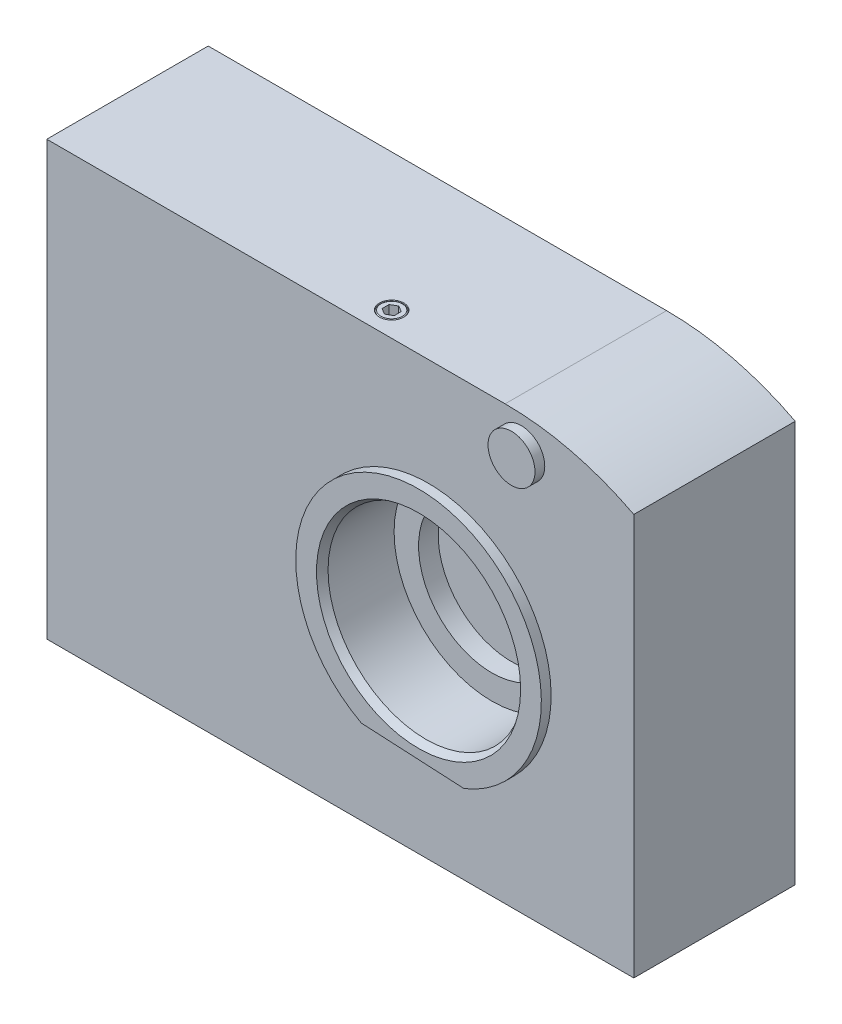
from build123d import *

# Parameters (mm, degrees)
BOSS_EXTRUDE1_DEPTH = 33
BOSS_EXTRUDE2_DEPTH = 2
CUT_EXTRUDE1_DEPTH  = 9.3
CUT_EXTRUDE2_DEPTH  = 9.3
CUT_EXTRUDE3_DEPTH  = 9.3
CUT_EXTRUDE4_DEPTH  = 9.3
SKETCH16_R          = 4.8
BOSS_EXTRUDE3_DEPTH = 2
CUT_EXTRUDE5_DEPTH  = 3


with BuildPart() as part:
    # Sketch1 → Boss-Extrude1 (new body)
    with BuildSketch(Plane.XY):
        with BuildLine():
            Line((0, 0), (120, 0))
            Line((120, 0), (120, 82.069852679))
            ThreePointArc((120, 82.069852679), (107.237326126, 86.869132207), (93.7, 88.5))
            Line((93.7, 88.5), (0, 88.5))
            Line((0, 88.5), (0, 0))
        make_face()
    extrude(amount=-BOSS_EXTRUDE1_DEPTH)

    # Sketch2 → Boss-Extrude2 (add)
    with BuildSketch(Plane.XY):
        with BuildLine():
            Line((66.324935076, 19.280574737), (87.288545319, 18.181918478))
            ThreePointArc((87.288545319, 18.181918478), (79.313632502, 66.565601322), (66.324935076, 19.280574737))
        make_face()
    extrude(amount=BOSS_EXTRUDE2_DEPTH)

    # Sketch3 → Cut-Revolve1 (revolve, cut)
    with BuildSketch(Plane(origin=(78, 0, 0), x_dir=(0, 0, -1), z_dir=(1, 0, 0))):
        Polygon((-2, 41.5), (-2, 62.366025404), (-0.5, 61.5), (13, 61.5), (13, 56.5), (17, 56.5), (17, 61.5), (28.5, 61.5), (30, 62.366025404), (30, 72.5), (33, 72.5), (33, 41.5), align=None)
    revolve(axis=Axis((78, 41.5, -33), (0, 0, 1)), mode=Mode.SUBTRACT)

    # Sketch4 → Cut-Revolve2 (revolve, cut)
    with BuildSketch(Plane(origin=(19.5, 0, 0), x_dir=(0, 0, -1), z_dir=(1, 0, 0))):
        Polygon((23.7, 8), (26.7, 11), (26.7, 12.4), (26.1, 13), (20.7, 13), (20.7, 13.5), (33, 13.5), (33, 8), align=None)
    revolve(axis=Axis((19.5, 8, -33), (0, 0, 1)), mode=Mode.SUBTRACT)

    # Sketch5 → Cut-Revolve3 (revolve, cut)
    with BuildSketch(Plane(origin=(103.5, 0, 0), x_dir=(0, 0, -1), z_dir=(1, 0, 0))):
        Polygon((23.7, 6.5), (26.7, 9.5), (26.7, 10.9), (26.1, 11.5), (20.7, 11.5), (20.7, 12), (33, 12), (33, 6.5), align=None)
    revolve(axis=Axis((103.5, 6.5, -33), (0, 0, 1)), mode=Mode.SUBTRACT)

    # Sketch6 → Cut-Revolve4 (revolve, cut)
    with BuildSketch(Plane(origin=(11.5, 0, 0), x_dir=(0, 0, -1), z_dir=(1, 0, 0))):
        Polygon((23.7, 58), (26.7, 61), (26.7, 62.4), (26.1, 63), (20.7, 63), (20.7, 63.5), (33, 63.5), (33, 58), align=None)
    revolve(axis=Axis((11.5, 58, -33), (0, 0, 1)), mode=Mode.SUBTRACT)

    # Sketch7 → Cut-Revolve5 (revolve, cut)
    with BuildSketch(Plane(origin=(107, 0, 0), x_dir=(0, 0, -1), z_dir=(1, 0, 0))):
        Polygon((23.7, 49), (26.7, 52), (26.7, 53.4), (26.1, 54), (20.7, 54), (20.7, 54.5), (33, 54.5), (33, 49), align=None)
    revolve(axis=Axis((107, 49, -33), (0, 0, 1)), mode=Mode.SUBTRACT)

    # Sketch8 → Cut-Extrude1 (cut)
    with BuildSketch(Plane.XY.offset(-33)):
        Polygon((17, 9.443375673), (17, 6.556624327), (19.5, 5.113248654), (22, 6.556624327), (22, 9.443375673), (19.5, 10.886751346), align=None)
    extrude(amount=CUT_EXTRUDE1_DEPTH, mode=Mode.SUBTRACT)

    # Sketch9 → Cut-Extrude2 (cut)
    with BuildSketch(Plane.XY.offset(-33)):
        Polygon((101, 7.943375673), (101, 5.056624327), (103.5, 3.613248654), (106, 5.056624327), (106, 7.943375673), (103.5, 9.386751346), align=None)
    extrude(amount=CUT_EXTRUDE2_DEPTH, mode=Mode.SUBTRACT)

    # Sketch10 → Cut-Extrude3 (cut)
    with BuildSketch(Plane.XY.offset(-33)):
        Polygon((9, 59.443375673), (9, 56.556624327), (11.5, 55.113248654), (14, 56.556624327), (14, 59.443375673), (11.5, 60.886751346), align=None)
    extrude(amount=CUT_EXTRUDE3_DEPTH, mode=Mode.SUBTRACT)

    # Sketch11 → Cut-Extrude4 (cut)
    with BuildSketch(Plane.XY.offset(-33)):
        Polygon((104.5, 50.443375673), (104.5, 47.556624327), (107, 46.113248654), (109.5, 47.556624327), (109.5, 50.443375673), (107, 51.886751346), align=None)
    extrude(amount=CUT_EXTRUDE4_DEPTH, mode=Mode.SUBTRACT)

    # Sketch12 → Cut-Revolve6 (revolve, cut)
    with BuildSketch(Plane(origin=(0, 14.5, 0), x_dir=(1, 0, 0), z_dir=(0, 1, 0))):
        Polygon((46, 11.480584363), (43.5415, 12.9), (43.5415, 32.4585), (43, 33), (46, 33), align=None)
    revolve(axis=Axis((46, 14.5, -33), (0, 0, 1)), mode=Mode.SUBTRACT)

    # Sketch13 → Cut-Revolve7 (revolve, cut)
    with BuildSketch(Plane(origin=(0, 14.5, 0), x_dir=(1, 0, 0), z_dir=(0, 1, 0))):
        Polygon((110, 11.480584363), (107.5415, 12.9), (107.5415, 32.4585), (107, 33), (110, 33), align=None)
    revolve(axis=Axis((110, 14.5, -33), (0, 0, 1)), mode=Mode.SUBTRACT)

    # Sketch14 → Cut-Revolve8 (revolve, cut)
    with BuildSketch(Plane(origin=(0, 68.5, 0), x_dir=(1, 0, 0), z_dir=(0, 1, 0))):
        Polygon((46, 11.480584363), (43.5415, 12.9), (43.5415, 32.4585), (43, 33), (46, 33), align=None)
    revolve(axis=Axis((46, 68.5, -33), (0, 0, 1)), mode=Mode.SUBTRACT)

    # Sketch15 → Cut-Revolve9 (revolve, cut)
    with BuildSketch(Plane(origin=(0, 68.5, 0), x_dir=(1, 0, 0), z_dir=(0, 1, 0))):
        Polygon((110, 11.480584363), (107.5415, 12.9), (107.5415, 32.4585), (107, 33), (110, 33), align=None)
    revolve(axis=Axis((110, 68.5, -33), (0, 0, 1)), mode=Mode.SUBTRACT)

    # Sketch16 → Boss-Extrude3 (add)
    with BuildSketch(Plane.XY):
        with Locations((97, 81.5)):
            Circle(SKETCH16_R)
    extrude(amount=BOSS_EXTRUDE3_DEPTH)

    # Sketch17 → Cut-Revolve10 (revolve, cut)
    with BuildSketch(Plane(origin=(65.5, 0, 0), x_dir=(0, 0, -1), z_dir=(1, 0, 0))):
        Polygon((5, 88.5), (2.806572993, 88.5), (2.612213504, 88.387786496), (2.5, 88.5), (2.5, 89.5), (5, 89.5), align=None)
    revolve(axis=Axis((65.5, 89.5, -5), (0, -1, 0)), mode=Mode.SUBTRACT)

    # Sketch18 → Revolve1 (revolve)
    with BuildSketch(Plane(origin=(78, 0, 0), x_dir=(0, 0, -1), z_dir=(1, 0, 0))):
        Polygon((17, 41.5), (17, 61.5), (30, 61.5), (30, 55.5), (38, 55.5), (41, 52.5), (41, 47.5), (57.5, 47.5), (58.5, 46.5), (58.5, 41.5), align=None)
    revolve(axis=Axis((78, 41.5, -58.5), (0, 0, 1)))

    # Sketch19 → Cut-Extrude5 (cut)
    with BuildSketch(Plane(origin=(0, 88.5, 0), x_dir=(1, 0, 0), z_dir=(0, 1, 0))):
        Polygon((64.25, 5.721687836), (64.25, 4.278312164), (65.5, 3.556624327), (66.75, 4.278312164), (66.75, 5.721687836), (65.5, 6.443375673), align=None)
    extrude(amount=-CUT_EXTRUDE5_DEPTH, mode=Mode.SUBTRACT)


solid = part.part
